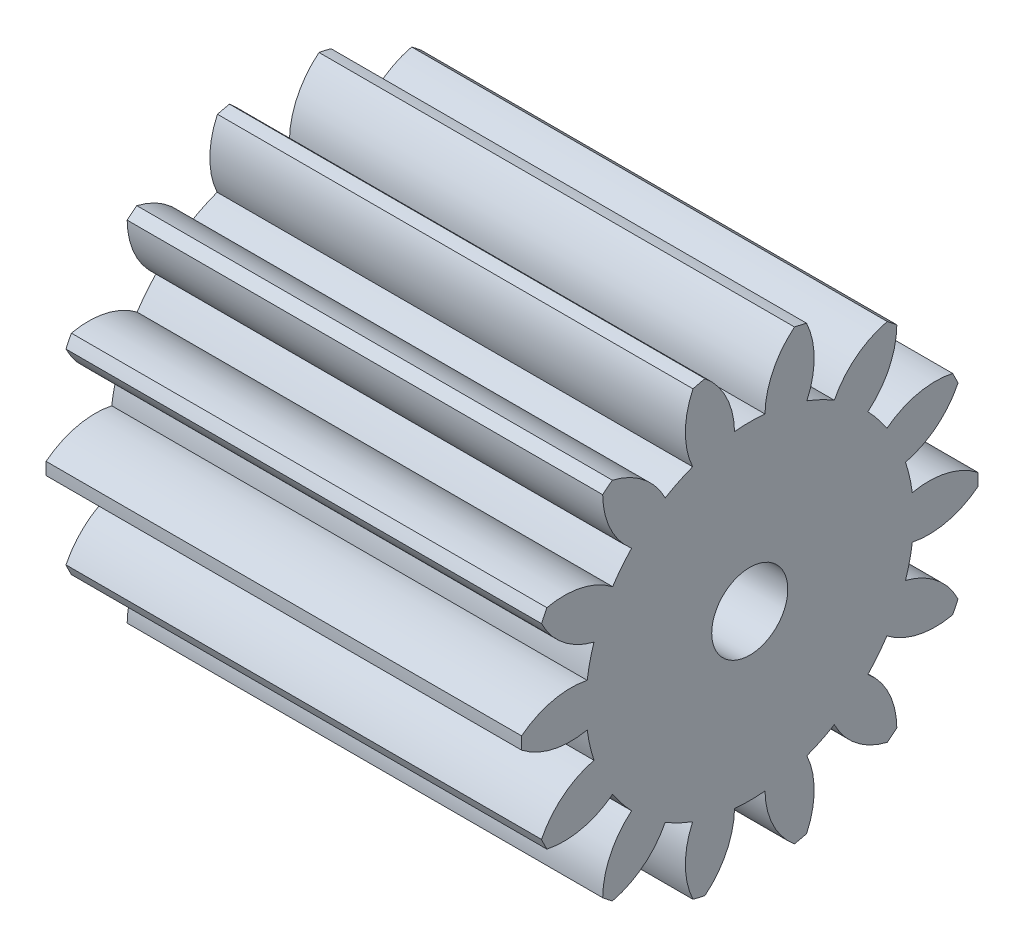
from build123d import *

# Parameters (mm, degrees)
BASPROSKE_W     = 5
BASPROSKE_H     = 2.4
TOOTHCUT_DEPTH  = 7.043177972
TEETHCUTS_COUNT = 14
TEETHCUTS_ANGLE = 334.285714286
BORSKE_R        = 0.4
BORE_DEPTH      = 50.0000508


with BuildPart() as part:
    # BasProSke → Base-Revolve (revolve)
    with BuildSketch(Plane(origin=(0, 0, 0), x_dir=(1, 0, 0), z_dir=(0, 1, 0)), mode=Mode.PRIVATE) as base_revolve_sk:
        with Locations((2.5, 1.2)):
            Rectangle(BASPROSKE_W, BASPROSKE_H)
    revolve(base_revolve_sk.sketch.rotate(Axis((-10, 0, 0), (1, 0, 0)), 180), axis=Axis((-10, 0, 0), (1, 0, 0)))

    # TooCutSke → ToothCut (cut, through all)
    with BuildSketch(Plane(origin=(0, 0, 0), x_dir=(0, 0, -1), z_dir=(1, 0, 0))):
        with BuildLine():
            ThreePointArc((0.160090817, 1.716550882), (0, 1.724), (-0.160090817, 1.716550882))
            ThreePointArc((-0.160090817, 1.716550882), (-0.252357177, 2.084260597), (-0.496900829, 2.373953396))
            ThreePointArc((-0.496900829, 2.373953396), (0, 2.4254), (0.496900829, 2.373953396))
            ThreePointArc((0.496900829, 2.373953396), (0.252357177, 2.084260597), (0.160090817, 1.716550882))
        make_face()
    toothcut = extrude(amount=TOOTHCUT_DEPTH, mode=Mode.SUBTRACT)

    # TeethCuts: ToothCut ×14 about axis
    teethcuts_axis = Axis((-10, 0, 0), (1, 0, 0))
    for i in range(1, TEETHCUTS_COUNT):
        add(toothcut.rotate(teethcuts_axis, i * TEETHCUTS_ANGLE / (TEETHCUTS_COUNT - 1)), mode=Mode.SUBTRACT)

    # BorSke → Bore (cut, symmetric)
    with BuildSketch(Plane(origin=(0, 0, 0), x_dir=(0, 0, -1), z_dir=(1, 0, 0))):
        with Locations(Location((0, 0, 0), (0, 0, 180))):
            Circle(BORSKE_R)
    extrude(amount=BORE_DEPTH, both=True, mode=Mode.SUBTRACT)


solid = part.part
